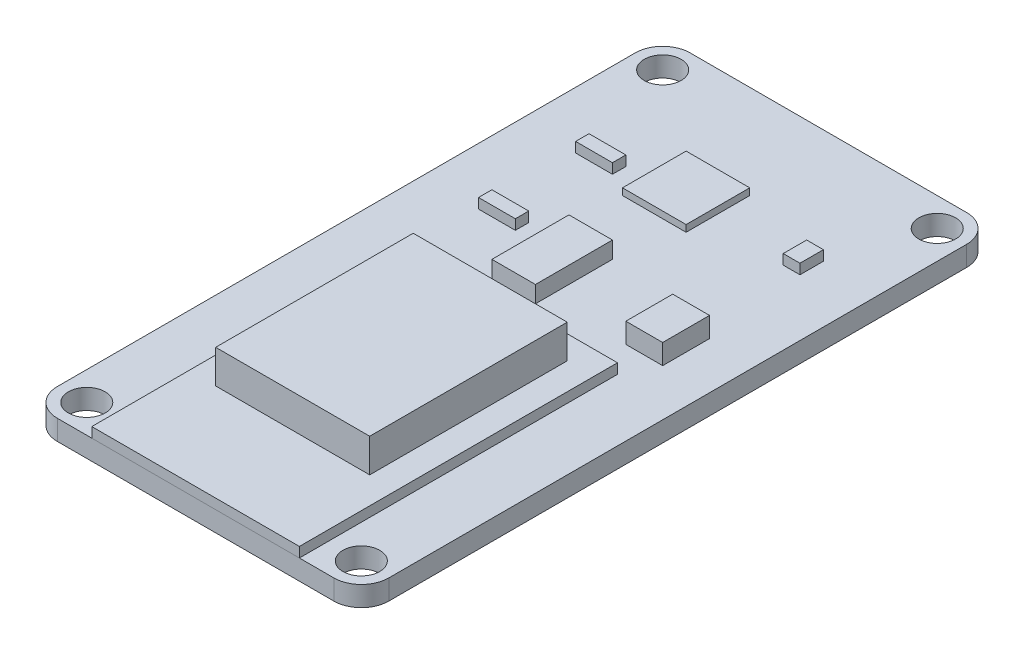
from build123d import *

# Parameters (mm, degrees)
SKETCH1_W           = 25.146
SKETCH1_H           = 48.006
BOSS_EXTRUDE1_DEPTH = 1.524
SKETCH3_W           = 15.748
SKETCH3_H           = 24.13
BOSS_EXTRUDE3_DEPTH = 0.762
SKETCH2_W           = 11.684
SKETCH2_H           = 14.986
BOSS_EXTRUDE2_DEPTH = 2.54
SKETCH6_R           = 1.397
CUT_EXTRUDE1_DEPTH  = 2.524
FILLET1_R           = 2.0828
SKETCH7_W           = 3.302
SKETCH7_H           = 5.842
BOSS_EXTRUDE4_DEPTH = 1.27
SKETCH8_W           = 4.826
SKETCH8_H           = 4.826
BOSS_EXTRUDE5_DEPTH = 0.508
SKETCH9_W           = 2.794
SKETCH9_H           = 3.556
BOSS_EXTRUDE6_DEPTH = 1.524
SKETCH10_W          = 2.794
SKETCH10_H          = 1.016
SKETCH10_W_2        = 1.27
SKETCH10_H_2        = 1.778
BOSS_EXTRUDE7_DEPTH = 0.762


with BuildPart() as part:
    # Sketch1 → Boss-Extrude1 (new body)
    with BuildSketch(Plane(origin=(0, 0, 0), x_dir=(1, 0, 0), z_dir=(0, 1, 0))):
        Rectangle(SKETCH1_W, SKETCH1_H)
    extrude(amount=BOSS_EXTRUDE1_DEPTH)

    # Sketch6 → Cut-Extrude1 (cut, through all)
    with BuildSketch(Plane(origin=(0, 1.524, 0), x_dir=(1, 0, 0), z_dir=(0, 1, 0))):
        with Locations((10.414, 21.844)):
            Circle(SKETCH6_R)
        with Locations((-10.414, 21.844)):
            Circle(SKETCH6_R)
        with Locations((-10.414, -21.844)):
            Circle(SKETCH6_R)
        with Locations((10.414, -21.844)):
            Circle(SKETCH6_R)
    extrude(amount=-CUT_EXTRUDE1_DEPTH, mode=Mode.SUBTRACT)

    # Fillet1
    fillet1_edges = [part.edges().sort_by_distance(p)[0] for p in [
        (12.573, 0.762, 24.003),
        (-12.573, 0.762, 24.003),
        (-12.573, 0.762, -24.003),
        (12.573, 0.762, -24.003),
    ]]
    fillet(fillet1_edges, radius=FILLET1_R)

    # Sketch7 → Boss-Extrude4 (add)
    with BuildSketch(Plane(origin=(0, 1.524, 0), x_dir=(1, 0, 0), z_dir=(0, 1, 0))):
        with Locations((-1.524, 4.572)):
            Rectangle(SKETCH7_W, SKETCH7_H)
    extrude(amount=BOSS_EXTRUDE4_DEPTH)

    # Sketch8 → Boss-Extrude5 (add)
    with BuildSketch(Plane(origin=(0, 1.524, 0), x_dir=(1, 0, 0), z_dir=(0, 1, 0))):
        with Locations((-1.27, 14.478)):
            Rectangle(SKETCH8_W, SKETCH8_H)
    extrude(amount=BOSS_EXTRUDE5_DEPTH)

    # Sketch9 → Boss-Extrude6 (add)
    with BuildSketch(Plane(origin=(0, 1.524, 0), x_dir=(1, 0, 0), z_dir=(0, 1, 0))):
        with Locations((7.62, 4.191)):
            Rectangle(SKETCH9_W, SKETCH9_H)
    extrude(amount=BOSS_EXTRUDE6_DEPTH)

    # Sketch10 → Boss-Extrude7 (add)
    with BuildSketch(Plane(origin=(0, 1.524, 0), x_dir=(1, 0, 0), z_dir=(0, 1, 0))):
        with Locations((-6.858, 6.223)):
            Rectangle(SKETCH10_W, SKETCH10_H)
        with Locations((-6.858, 13.589)):
            Rectangle(SKETCH10_W, SKETCH10_H)
        with Locations((7.62, 14.478)):
            Rectangle(SKETCH10_W_2, SKETCH10_H_2)
    extrude(amount=BOSS_EXTRUDE7_DEPTH)


with BuildPart() as body_2:
    # Sketch3 → Boss-Extrude3 (new body)
    with BuildSketch(Plane(origin=(0, 1.524, 0), x_dir=(1, 0, 0), z_dir=(0, 1, 0))):
        with Locations((0, -11.938)):
            Rectangle(SKETCH3_W, SKETCH3_H)
    extrude(amount=BOSS_EXTRUDE3_DEPTH)


with BuildPart() as body_3:
    # Sketch2 → Boss-Extrude2 (new body)
    with BuildSketch(Plane(origin=(0, 2.286, 0), x_dir=(1, 0, 0), z_dir=(0, 1, 0))):
        with Locations((0, -9.144)):
            Rectangle(SKETCH2_W, SKETCH2_H)
    extrude(amount=BOSS_EXTRUDE2_DEPTH)


solid = Compound([part.part, body_2.part, body_3.part])
